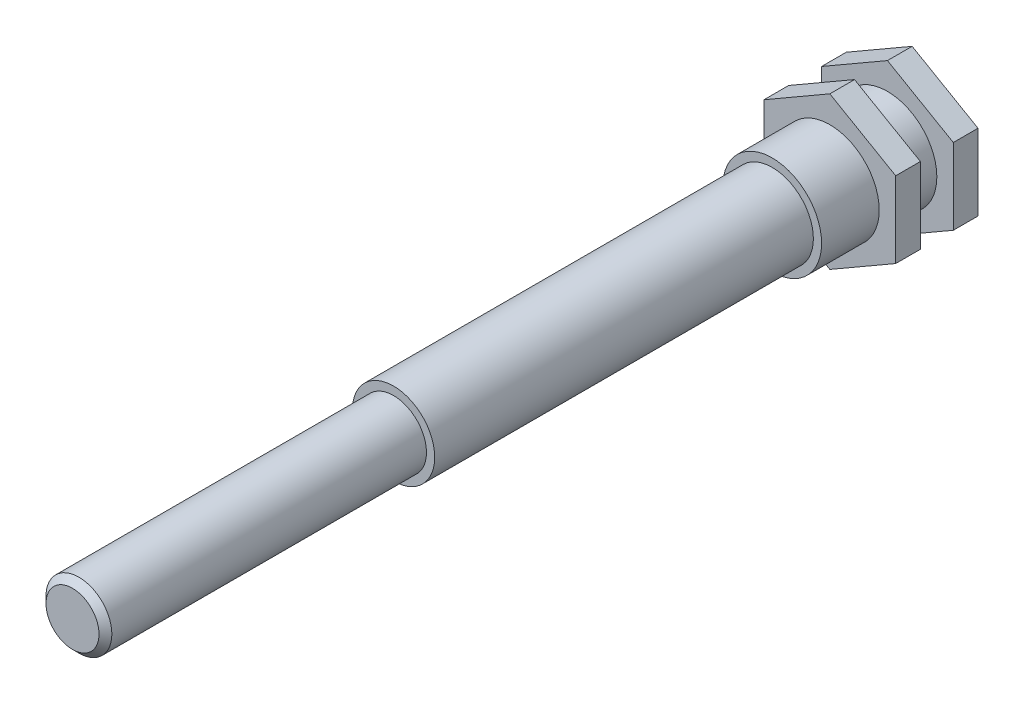
from build123d import *

# Parameters (mm, degrees)
EXTRUDE_1_DEPTH = 1.5
SKETCH_2_R      = 3
EXTRUDE_2_DEPTH = 7
EXTRUDE_START   = 3.5
EXTRUDE_3_DEPTH = 1.5
SKETCH_3_R      = 2.5
EXTRUDE_4_DEPTH = 23
SKETCH_4_R      = 2
EXTRUDE_5_DEPTH = 19.5
CHAMFER_1_SIZE  = 0.39


with BuildPart() as part:
    # Эскиз1 → Бобышка-Вытянуть1 (new body)
    with BuildSketch(Plane.XY):
        Polygon((-4, 2.309401077), (-4, -2.309401077), (0, -4.618802154), (4, -2.309401077), (4, 2.309401077), (0, 4.618802154), align=None)
    extrude(amount=EXTRUDE_1_DEPTH)

    # Эскиз2 → Бобышка-Вытянуть2 (add)
    with BuildSketch(Plane.XY.offset(1.5)):
        Circle(SKETCH_2_R)
    extrude(amount=EXTRUDE_2_DEPTH)

    # Эскиз1<2> → Бобышка-Вытянуть3 (add)
    with BuildSketch(Plane.XY.offset(EXTRUDE_START)):
        Polygon((-4, 2.309401077), (-4, -2.309401077), (0, -4.618802154), (4, -2.309401077), (4, 2.309401077), (0, 4.618802154), align=None)
    extrude(amount=EXTRUDE_3_DEPTH)

    # Эскиз3 → Бобышка-Вытянуть4 (add)
    with BuildSketch(Plane.XY.offset(8.5)):
        Circle(SKETCH_3_R)
    extrude(amount=EXTRUDE_4_DEPTH)

    # Эскиз4 → Бобышка-Вытянуть5 (add)
    with BuildSketch(Plane.XY.offset(31.5)):
        Circle(SKETCH_4_R)
    extrude(amount=EXTRUDE_5_DEPTH)

    # Фаска1
    chamfer_1_edges = [part.edges().sort_by_distance(p)[0] for p in [
        (-2, 0, 51),
    ]]
    chamfer(chamfer_1_edges, length=CHAMFER_1_SIZE)


solid = part.part
